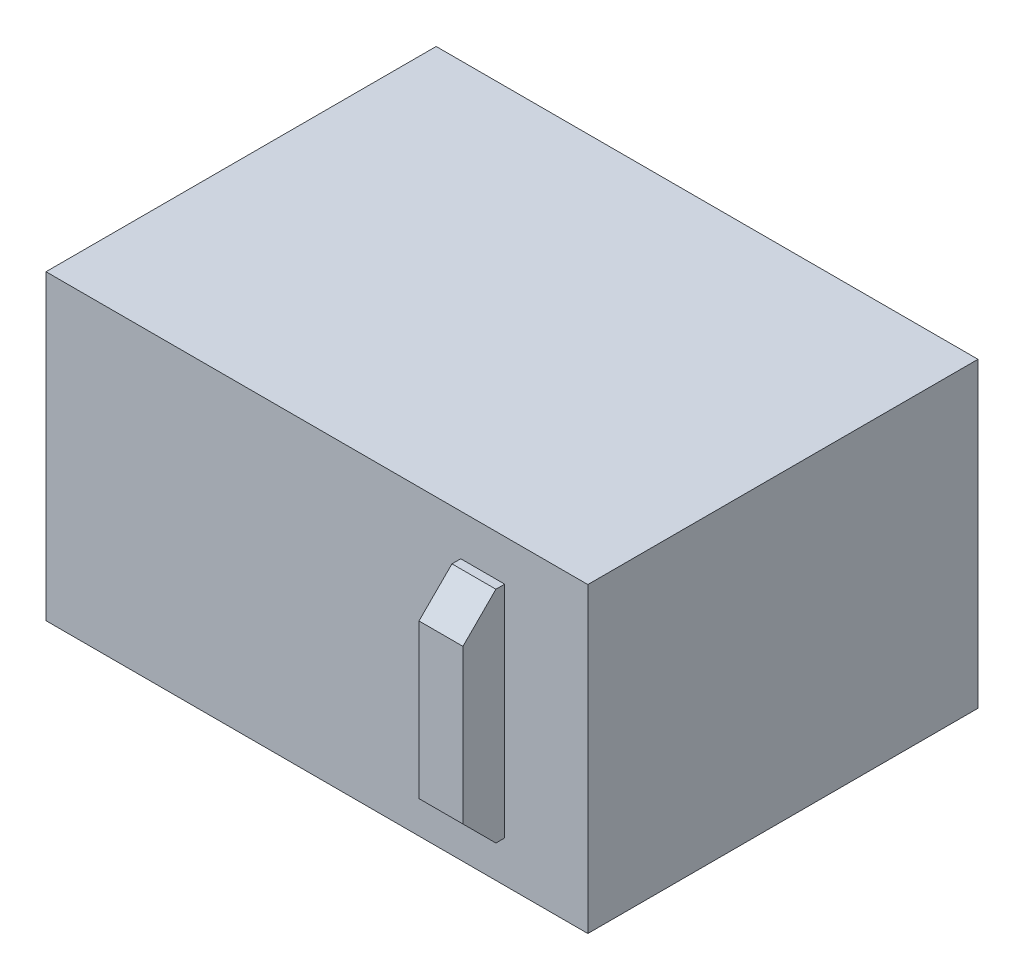
from build123d import *

# Parameters (mm, degrees)
SKETCH1_W           = 493
SKETCH1_H           = 355
BOSS_EXTRUDE1_DEPTH = 275
SKETCH2_W           = 40
SKETCH2_H           = 200
BOSS_EXTRUDE2_DEPTH = 38
CHAMFER1_SIZE       = 30


with BuildPart() as part:
    # Sketch1 → Boss-Extrude1 (new body)
    with BuildSketch(Plane(origin=(0, 0, 0), x_dir=(1, 0, 0), z_dir=(0, 1, 0))):
        Rectangle(SKETCH1_W, SKETCH1_H)
    extrude(amount=BOSS_EXTRUDE1_DEPTH)

    # Sketch2 → Boss-Extrude2 (add)
    with BuildSketch(Plane.XY.offset(177.5)):
        with Locations((150.868479839, 137.5)):
            Rectangle(SKETCH2_W, SKETCH2_H)
    extrude(amount=BOSS_EXTRUDE2_DEPTH)

    # Chamfer1
    chamfer1_edges = [part.edges().sort_by_distance(p)[0] for p in [
        (150.868479839, 37.5, 215.5),
        (150.868479839, 237.5, 215.5),
    ]]
    chamfer(chamfer1_edges, length=CHAMFER1_SIZE)


solid = part.part
